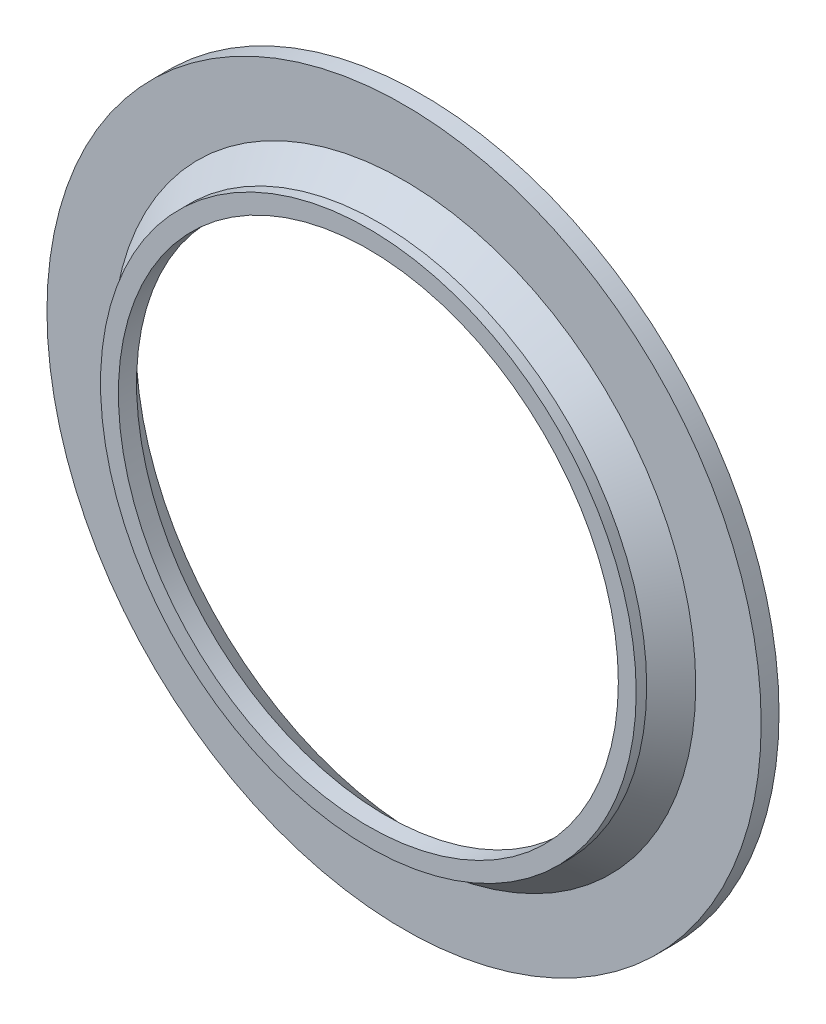
from build123d import *


with BuildPart() as part:
    # Sketch1 → Revolve1 (revolve)
    with BuildSketch(Plane(origin=(0, 0, 0), x_dir=(1, 0, 0), z_dir=(0, 1, 0))):
        Polygon((1.5, 0), (1.5, 0.058756175), (1.633505434, 0.2), (2, 0.2), (2, 0.3), (1.601991028, 0.3), (1.4, 0.101718501), (1.4, 0), align=None)
    revolve(axis=Axis((0, 0, 0), (0, 0, -1)))


solid = part.part
